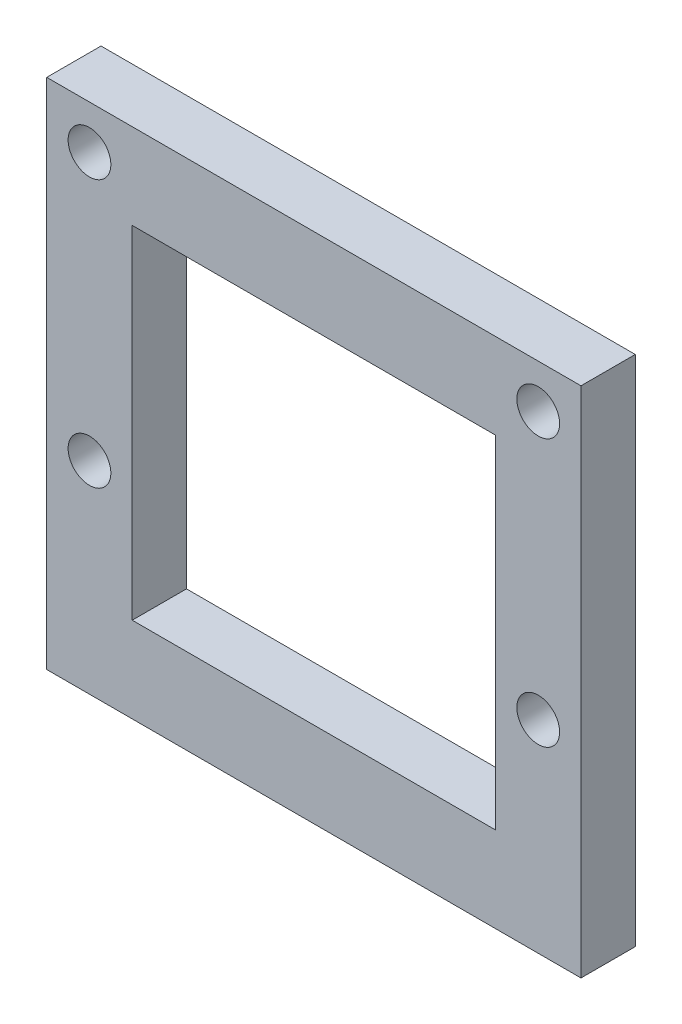
from build123d import *

# Parameters (mm, degrees)
SKETCH1_W           = 25.0000008
SKETCH1_H           = 24.00000026
SKETCH1_W_2         = 17.000000544
SKETCH1_H_2         = 16.000000004
BOSS_EXTRUDE1_DEPTH = 2.54
SKETCH2_R           = 1.000000032
CUT_EXTRUDE1_DEPTH  = 2.54


with BuildPart() as part:
    # Sketch1 → Boss-Extrude1 (new body)
    with BuildSketch(Plane.XY):
        Rectangle(SKETCH1_W, SKETCH1_H)
        Rectangle(SKETCH1_W_2, SKETCH1_H_2, mode=Mode.SUBTRACT)
    extrude(amount=BOSS_EXTRUDE1_DEPTH)

    # Sketch2 → Cut-Extrude1 (cut)
    with BuildSketch(Plane.XY.offset(0.635)):
        with Locations((-10.500000336, 9.963437842)):
            Circle(SKETCH2_R)
        with Locations((-10.500000336, -2.536562558)):
            Circle(SKETCH2_R)
        with Locations((10.500000336, 9.963437842)):
            Circle(SKETCH2_R)
        with Locations((10.500000336, -2.536562558)):
            Circle(SKETCH2_R)
    extrude(amount=CUT_EXTRUDE1_DEPTH, mode=Mode.SUBTRACT)


solid = part.part
